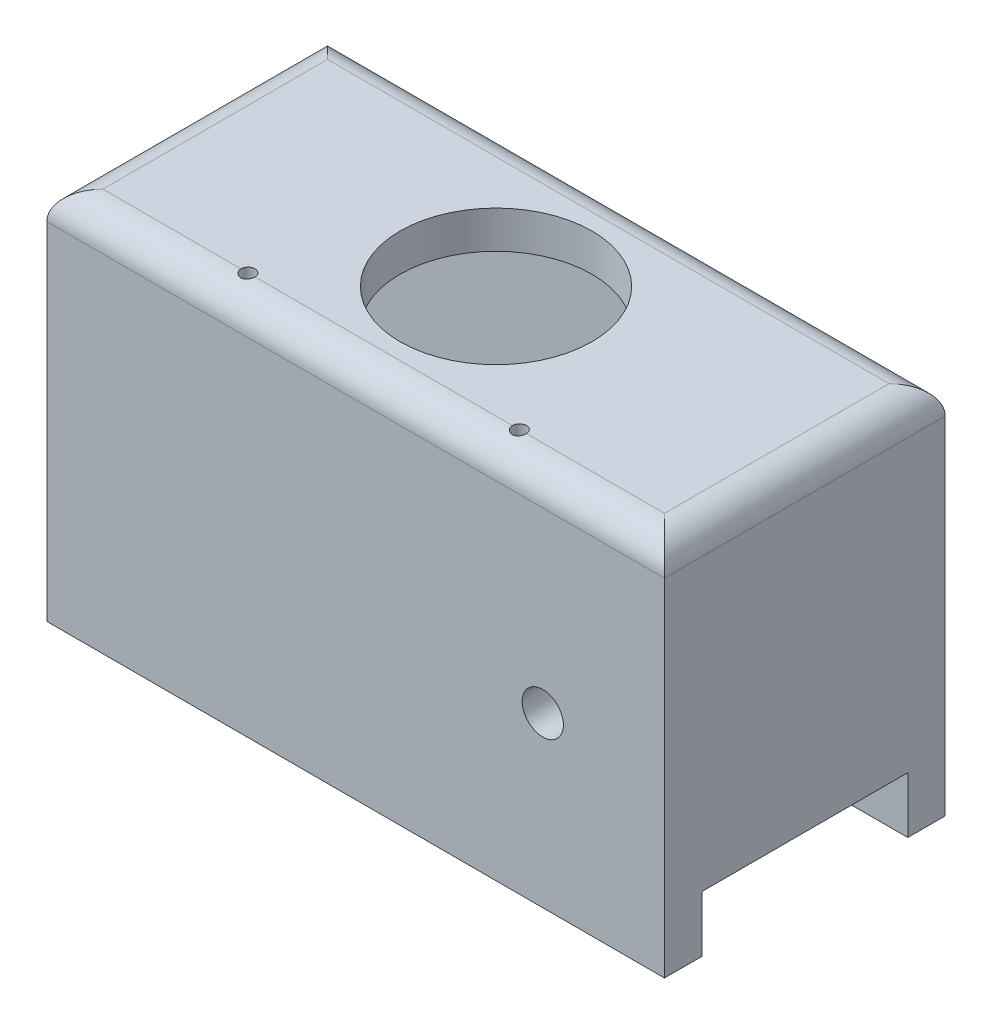
from build123d import *

# Parameters (mm, degrees)
SKETCH1_W           = 66
SKETCH1_H           = 30
BOSS_EXTRUDE1_DEPTH = 4
FILLET1_R           = 3
SKETCH2_W           = 66
SKETCH2_H           = 30
SKETCH2_W_2         = 58
SKETCH2_H_2         = 22
BOSS_EXTRUDE2_DEPTH = 30
SKETCH3_R           = 10.25
CUT_EXTRUDE1_DEPTH  = 35
SKETCH4_R           = 0.75
CUT_EXTRUDE2_DEPTH  = 35
SKETCH5_W           = 66
SKETCH5_H           = 4
BOSS_EXTRUDE4_DEPTH = 6
SKETCH6_R           = 2.2
CUT_EXTRUDE3_DEPTH  = 6


with BuildPart() as part:
    # Sketch1 → Boss-Extrude1 (new body)
    with BuildSketch(Plane(origin=(0, 0, 0), x_dir=(1, 0, 0), z_dir=(0, 1, 0))):
        with Locations((-33, -15)):
            Rectangle(SKETCH1_W, SKETCH1_H)
    extrude(amount=BOSS_EXTRUDE1_DEPTH)

    # Fillet1
    fillet1_edges = [part.edges().sort_by_distance(p)[0] for p in [
        (-66, 4, 15),
        (-33, 4, 30),
        (0, 4, 15),
        (-33, 4, 0),
    ]]
    fillet(fillet1_edges, radius=FILLET1_R)

    # Sketch2 → Boss-Extrude2 (add)
    with BuildSketch(Plane.XZ):
        with Locations((-33, 15)):
            Rectangle(SKETCH2_W, SKETCH2_H)
        with Locations((-33, 15)):
            Rectangle(SKETCH2_W_2, SKETCH2_H_2, mode=Mode.SUBTRACT)
    extrude(amount=BOSS_EXTRUDE2_DEPTH)

    # Sketch3 → Cut-Extrude1 (cut, through all)
    with BuildSketch(Plane(origin=(0, 4, 0), x_dir=(1, 0, 0), z_dir=(0, 1, 0))):
        with Locations((-33, -15)):
            Circle(SKETCH3_R)
    extrude(amount=-CUT_EXTRUDE1_DEPTH, mode=Mode.SUBTRACT)

    # Sketch4 → Cut-Extrude2 (cut, through all)
    with BuildSketch(Plane(origin=(0, 4, 0), x_dir=(1, 0, 0), z_dir=(0, 1, 0))):
        with Locations((-47.5, -27)):
            Circle(SKETCH4_R)
        with Locations((-18.5, -27)):
            Circle(SKETCH4_R)
    extrude(amount=-CUT_EXTRUDE2_DEPTH, mode=Mode.SUBTRACT)

    # Sketch5 → Boss-Extrude4 (add)
    with BuildSketch(Plane.XZ.offset(30)):
        with Locations((-33, 28)):
            Rectangle(SKETCH5_W, SKETCH5_H)
        with Locations((-33, 2)):
            Rectangle(SKETCH5_W, SKETCH5_H)
    extrude(amount=BOSS_EXTRUDE4_DEPTH)

    # Sketch6 → Cut-Extrude3 (cut)
    with BuildSketch(Plane.XY.offset(30)):
        with Locations((-13, -18)):
            Circle(SKETCH6_R)
    extrude(amount=-CUT_EXTRUDE3_DEPTH, mode=Mode.SUBTRACT)


solid = part.part
